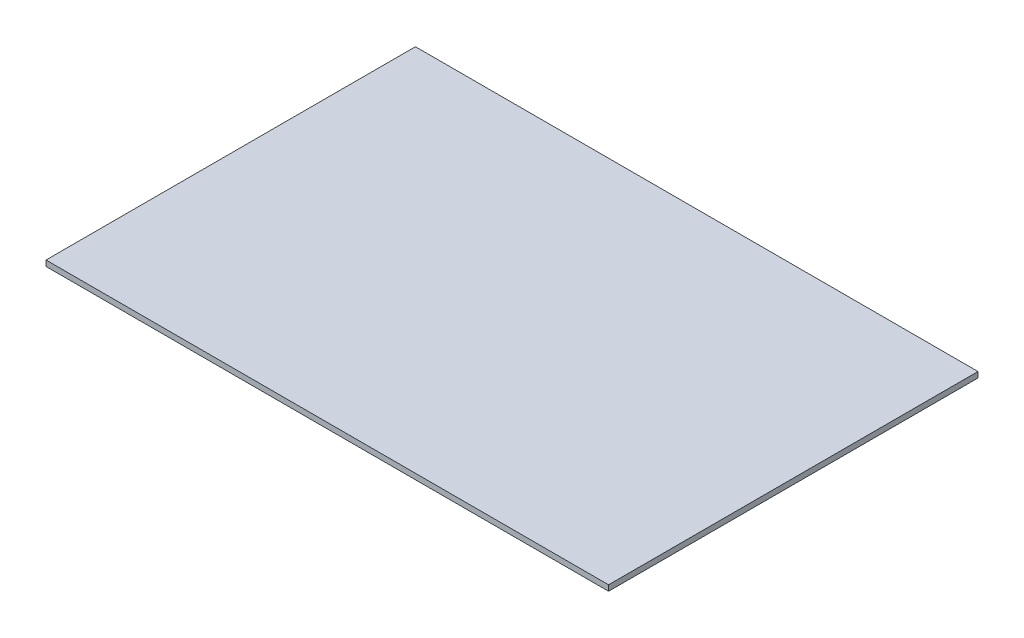
from build123d import *

# Parameters (mm, degrees)
SKETCH1_W           = 300
SKETCH1_H           = 197
BOSS_EXTRUDE1_DEPTH = 3


with BuildPart() as part:
    # Sketch1 → Boss-Extrude1 (new body)
    with BuildSketch(Plane(origin=(0, 0, 0), x_dir=(1, 0, 0), z_dir=(0, 1, 0))):
        Rectangle(SKETCH1_W, SKETCH1_H)
    extrude(amount=BOSS_EXTRUDE1_DEPTH)


solid = part.part
